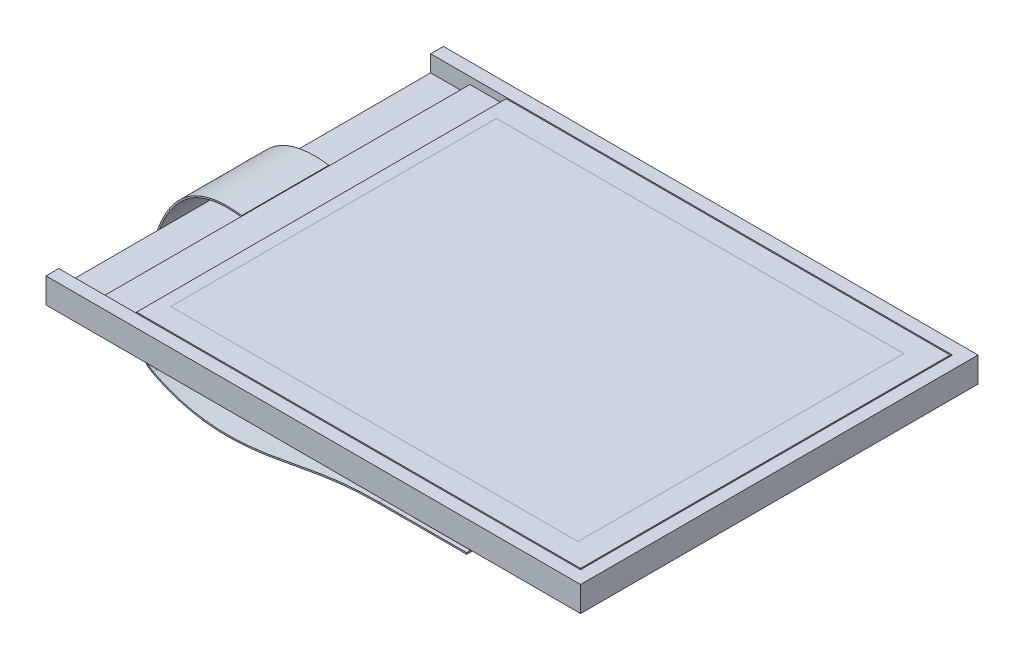
from build123d import *

# Parameters (mm, degrees)
SKETCH1_W           = 45.8
SKETCH1_H           = 34
BOSS_EXTRUDE1_DEPTH = 2.17
SKETCH2_W           = 44.8
SKETCH2_H           = 32
CUT_EXTRUDE1_DEPTH  = 1.42
SKETCH3_W           = 41.32
SKETCH3_H           = 31.8
BOSS_EXTRUDE3_DEPTH = 1.42
SKETCH10_W          = 3.12
SKETCH10_H          = 31.8
CUT_EXTRUDE2_DEPTH  = 0.5
SKETCH6_W           = 7.5
SKETCH6_H           = 0.125
MOVE_FACE1_BY       = 0.1
MOVE_FACE1_2_BY     = 0.1
MOVE_FACE1_3_BY     = 0.1
MOVE_FACE1_4_BY     = 0.1


with BuildPart() as part:
    # Sketch1 → Boss-Extrude1 (new body)
    with BuildSketch(Plane(origin=(0, 0, 0), x_dir=(1, 0, 0), z_dir=(0, 1, 0))):
        Rectangle(SKETCH1_W, SKETCH1_H)
    extrude(amount=BOSS_EXTRUDE1_DEPTH)

    # Sketch2 → Cut-Extrude1 (cut)
    with BuildSketch(Plane(origin=(0, 2.17, 0), x_dir=(1, 0, 0), z_dir=(0, 1, 0))):
        with Locations((-0.5, 0)):
            Rectangle(SKETCH2_W, SKETCH2_H)
    extrude(amount=-CUT_EXTRUDE1_DEPTH, mode=Mode.SUBTRACT)

    # Move Face1: a face moved outward by 0.1
    extrude(part.faces().sort_by_distance((-22.9, 0.483729711, 0))[0], amount=MOVE_FACE1_BY, dir=(-1, 0, 0))

    # Move Face1 2: a face moved outward by 0.1
    extrude(part.faces().sort_by_distance((0, 1.085, -17))[0], amount=MOVE_FACE1_2_BY, dir=(0, 0, -1))

    # Move Face1 3: a face moved outward by 0.1
    extrude(part.faces().sort_by_distance((22.9, 1.085, 0))[0], amount=MOVE_FACE1_3_BY, dir=(1, 0, 0))

    # Move Face1 4: a face moved outward by 0.1
    extrude(part.faces().sort_by_distance((0, 1.085, 17))[0], amount=MOVE_FACE1_4_BY, dir=(0, 0, 1))


with BuildPart() as body_2:
    # Sketch3 → Boss-Extrude3 (new body)
    with BuildSketch(Plane(origin=(0, 0.75, 0), x_dir=(1, 0, 0), z_dir=(0, 1, 0))):
        with Locations((1.14, 0)):
            Rectangle(SKETCH3_W, SKETCH3_H)
    extrude(amount=BOSS_EXTRUDE3_DEPTH)

    # Sketch10 → Cut-Extrude2 (cut)
    with BuildSketch(Plane(origin=(0, 2.17, 0), x_dir=(1, 0, 0), z_dir=(0, 1, 0))):
        with Locations((-17.96, 0)):
            Rectangle(SKETCH10_W, SKETCH10_H)
    extrude(amount=-CUT_EXTRUDE2_DEPTH, mode=Mode.SUBTRACT)


with BuildPart() as body_3:
    # Sweep1: sweep along a path in Sketch5
    with BuildLine() as sweep1_path:  # in the path sketch's own coordinates; laid on its plane below (add() does not lay a ready-made edge on the line's plane)
        Line((-0.150030463, -13.77), (-7.650030463, -13.77))
        add(Edge.make_bspline(
            [(-7.650030463, -13.77), (-11.191284234, -13.77), (-16.452701483, -15.032914926), (-23.188655813, -15.825499155), (-27.150030463, -13.77)],
            knots=[0, 0, 0, 0, 0.425975672, 1, 1, 1, 1], degree=3))
        add(Edge.make_bspline(
            [(-27.150030463, -13.77), (-28.801890413, -12.91287412), (-28.41126063, -9.69743297), (-26.311115961, -0.725614859), (-23.47041501, 2.232100695), (-19.52, 1.67)],
            knots=[0, 0, 0, 0, 0.519171968, 0.661296858, 1, 1, 1, 1], degree=3))
    # Sketch6 → Sweep1 (sweep)
    with BuildSketch(Plane(origin=(-0.150030463, 0, 0), x_dir=(0, 0, -1), z_dir=(1, 0, 0))):
        with Locations((0, -13.77)):
            Rectangle(SKETCH6_W, SKETCH6_H)
    sweep(path=Plane.XY * sweep1_path.line)


solid = Compound([part.part, body_2.part, body_3.part])
